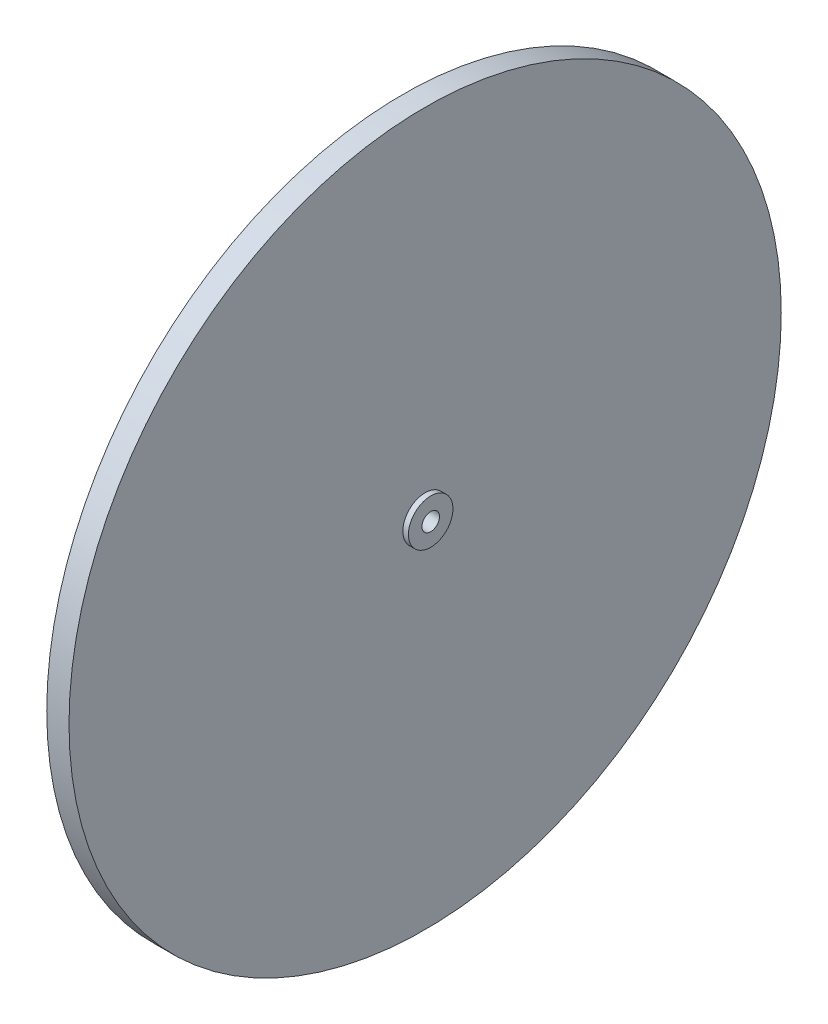
from build123d import *


with BuildPart() as part:
    # Sketch1 → Revolve1 (revolve)
    with BuildSketch(Plane.XY):
        Polygon((0, 6.35), (1.5875, 6.35), (1.5875, 101.6), (7.9375, 101.6), (7.9375, 6.35), (9.525, 6.35), (9.525, 2.5), (0, 2.5), align=None)
    revolve(axis=Axis((0, 0, 0), (1, 0, 0)))


solid = part.part
